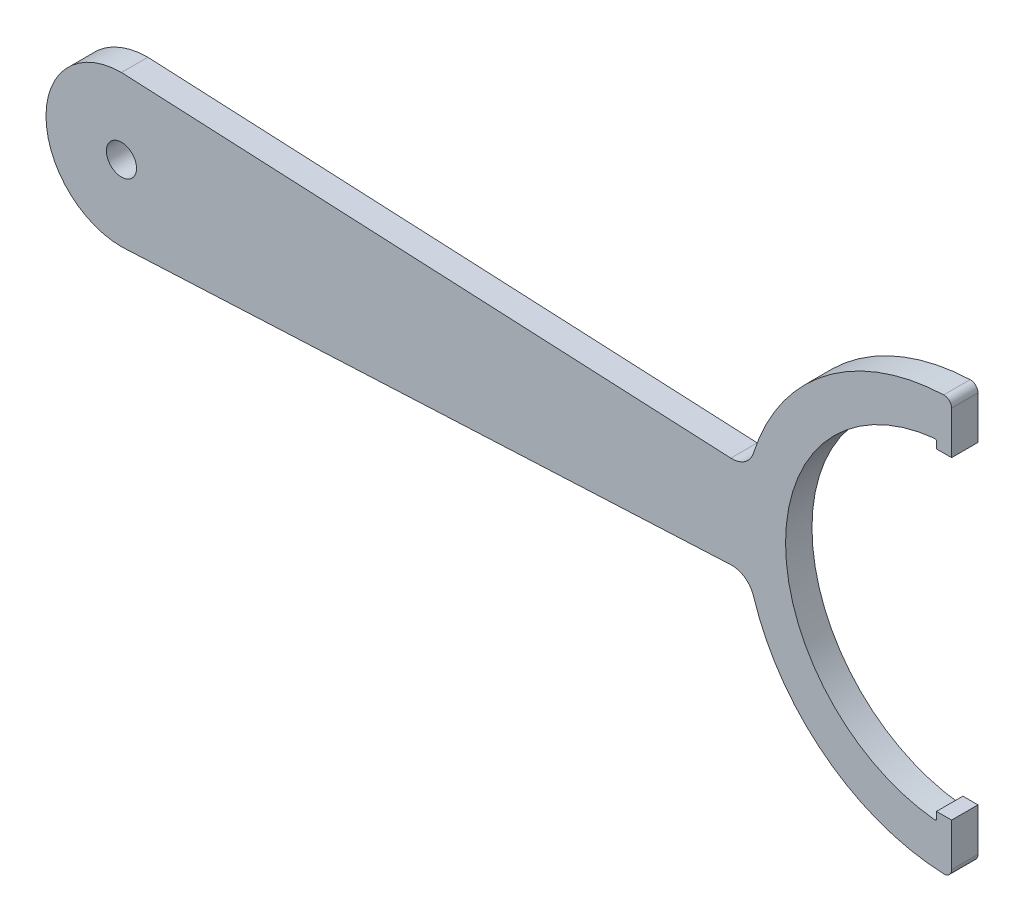
from build123d import *

# Parameters (mm, degrees)
EXTRUSION1_DEPTH = 3.5
CONG_1_R         = 3
CONG_2_R         = 3
CONG_3_R         = 1
CONG_4_R         = 1
CONG_7_R         = 0.2
CONG_8_R         = 0.2
ESQUISSE2_R      = 2
EXTRUSION2_DEPTH = 3.5


with BuildPart() as part:
    # Esquisse1 → Extrusion1 (new body)
    with BuildSketch(Plane.XY):
        with BuildLine():
            Line((0, 10), (83.162526199, 6))
            ThreePointArc((83.162526199, 6), (92.806251136, 21.462176031), (110, 27.5))
            Line((110, 27.5), (110, 20.794494718))
            Line((110, 20.794494718), (108, 20.794494718))
            Line((108, 20.794494718), (108, 21.9089023))
            ThreePointArc((108, 21.9089023), (88, 0), (108, -21.9089023))
            Line((108, -21.9089023), (108, -20.794494718))
            Line((108, -20.794494718), (110, -20.794494718))
            Line((110, -20.794494718), (110, -27.5))
            ThreePointArc((110, -27.5), (92.806251136, -21.462176031), (83.162526199, -6))
            Line((83.162526199, -6), (0, -10))
            ThreePointArc((0, -10), (-10, 0), (0, 10))
        make_face()
    extrude(amount=EXTRUSION1_DEPTH)

    # Congé1
    cong_1_edges = [part.edges().sort_by_distance(p)[0] for p in [
        (83.162526199, 6, 1.75),
    ]]
    fillet(cong_1_edges, radius=CONG_1_R)

    # Congé2
    cong_2_edges = [part.edges().sort_by_distance(p)[0] for p in [
        (83.162526199, -6, 1.75),
    ]]
    fillet(cong_2_edges, radius=CONG_2_R)

    # Congé3
    cong_3_edges = [part.edges().sort_by_distance(p)[0] for p in [
        (110, 27.5, 1.75),
    ]]
    fillet(cong_3_edges, radius=CONG_3_R)

    # Congé4
    cong_4_edges = [part.edges().sort_by_distance(p)[0] for p in [
        (110, -27.5, 1.75),
    ]]
    fillet(cong_4_edges, radius=CONG_4_R)

    # Congé7
    cong_7_edges = [part.edges().sort_by_distance(p)[0] for p in [
        (108, -21.9089023, 1.75),
    ]]
    fillet(cong_7_edges, radius=CONG_7_R)

    # Congé8
    cong_8_edges = [part.edges().sort_by_distance(p)[0] for p in [
        (108, 21.9089023, 1.75),
    ]]
    fillet(cong_8_edges, radius=CONG_8_R)

    # Esquisse2 → Extrusion2 (cut)
    with BuildSketch(Plane.XY.offset(3.5)):
        Circle(ESQUISSE2_R)
    extrude(amount=-EXTRUSION2_DEPTH, mode=Mode.SUBTRACT)


solid = part.part
